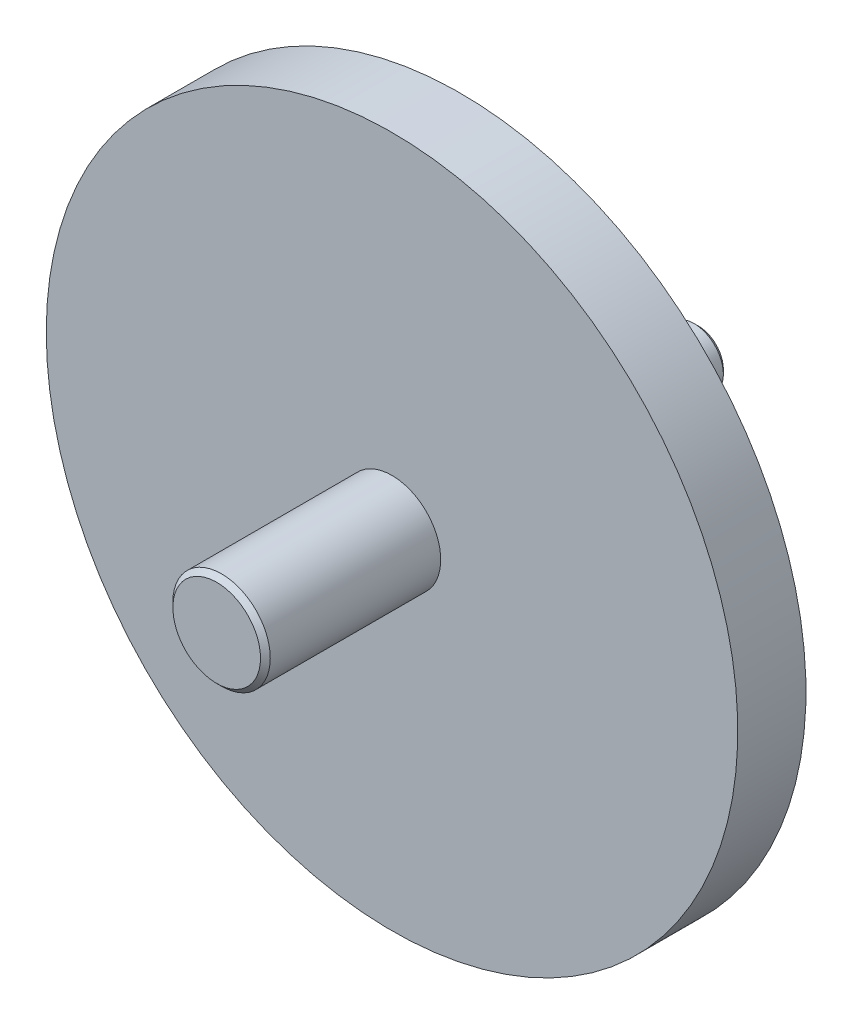
from build123d import *

# Parameters (mm, degrees)
CHAFL_N1_SIZE = 0.45
CHAFL_N2_SIZE = 0.5


with BuildPart() as part:
    # Croquis1 → Revolución1 (revolve)
    with BuildSketch(Plane(origin=(0, 0, 0), x_dir=(0, 0, -1), z_dir=(1, 0, 0))):
        with BuildLine():
            Line((0, 0), (0, 5))
            Line((0, 5), (18, 5))
            Line((18, 5), (18, 35.5))
            Line((18, 35.5), (25, 35.5))
            Line((25, 35.5), (25, 5))
            ThreePointArc((25, 5), (25.8, 4.2), (26.6, 5))
            Line((26.6, 5), (33, 5))
            Line((33, 5), (40.464101615, 3))
            Line((40.464101615, 3), (49.464101615, 3))
            Line((49.464101615, 3), (49.464101615, 0))
            Line((49.464101615, 0), (0, 0))
        make_face()
    revolve(axis=Axis((0, 0, -49.464101615), (0, 0, 1)))

    # Chaflán1
    chafl_n1_edges = [part.edges().sort_by_distance(p)[0] for p in [
        (0, -3, -49.464101615),
    ]]
    chamfer(chafl_n1_edges, length=CHAFL_N1_SIZE)

    # Chaflán2
    chafl_n2_edges = [part.edges().sort_by_distance(p)[0] for p in [
        (0, -5, 0),
    ]]
    chamfer(chafl_n2_edges, length=CHAFL_N2_SIZE)


solid = part.part
